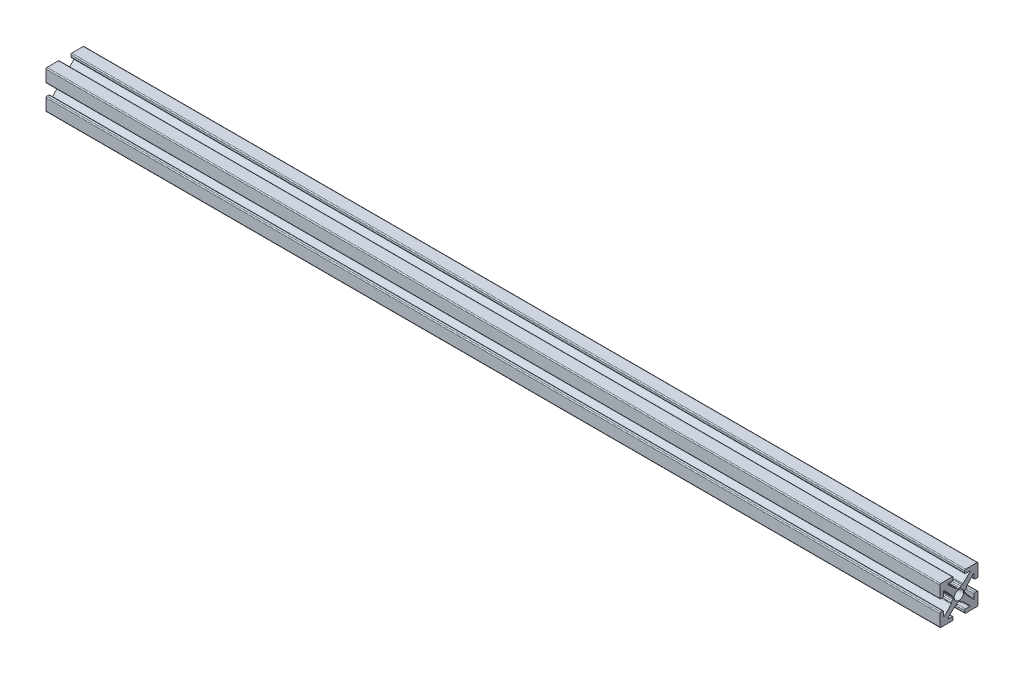
from build123d import *

# Parameters (mm, degrees)
ESTRUSIONE_ESTRUSIONE1_DEPTH = 234.4674
FORO_FILETTATO_M3X0_5_1_D    = 2.5


with BuildPart() as part:
    # Sketch1 → Estrusione-Estrusione1 (new body)
    with BuildSketch(Plane(origin=(0, 0, 0), x_dir=(0, 0, -1), z_dir=(1, 0, 0))):
        with BuildLine():
            Line((-0.2413, 1.4986), (0.2413, 1.4986))
            ThreePointArc((0.2413, 1.4986), (0.420905122, 1.572994878), (0.4953, 1.7526))
            ThreePointArc((0.4953, 1.7526), (0.569694878, 1.932205122), (0.7493, 2.0066))
            Line((0.7493, 2.0066), (0.889923986, 2.0066))
            ThreePointArc((0.889923986, 2.0066), (0.983516259, 2.024471886), (1.063937899, 2.075572548))
            Line((1.063937899, 2.075572548), (2.890793, 3.793686274))
            ThreePointArc((2.890793, 3.793686274), (2.921850101, 3.932996137), (2.803786044, 4.0132))
            Line((2.803786044, 4.0132), (1.7526, 4.0132))
            ThreePointArc((1.7526, 4.0132), (1.572994878, 4.087594878), (1.4986, 4.2672))
            Line((1.4986, 4.2672), (1.4986, 4.7498))
            ThreePointArc((1.4986, 4.7498), (1.572994878, 4.929405122), (1.7526, 5.0038))
            Line((1.7526, 5.0038), (4.7498, 5.0038))
            ThreePointArc((4.7498, 5.0038), (4.929405122, 4.929405122), (5.0038, 4.7498))
            Line((5.0038, 4.7498), (5.0038, 1.7526))
            ThreePointArc((5.0038, 1.7526), (4.929405122, 1.572994878), (4.7498, 1.4986))
            Line((4.7498, 1.4986), (4.2672, 1.4986))
            ThreePointArc((4.2672, 1.4986), (4.087594878, 1.572994878), (4.0132, 1.7526))
            Line((4.0132, 1.7526), (4.0132, 2.803786044))
            ThreePointArc((4.0132, 2.803786044), (3.932996137, 2.921850101), (3.793686274, 2.890793))
            Line((3.793686274, 2.890793), (2.075572548, 1.063937899))
            ThreePointArc((2.075572548, 1.063937899), (2.024471886, 0.983516259), (2.0066, 0.889923986))
            Line((2.0066, 0.889923986), (2.0066, 0.7493))
            ThreePointArc((2.0066, 0.7493), (1.932205122, 0.569694878), (1.7526, 0.4953))
            ThreePointArc((1.7526, 0.4953), (1.572994878, 0.420905122), (1.4986, 0.2413))
            Line((1.4986, 0.2413), (1.4986, -0.2413))
            ThreePointArc((1.4986, -0.2413), (1.572994878, -0.420905122), (1.7526, -0.4953))
            ThreePointArc((1.7526, -0.4953), (1.932205122, -0.569694878), (2.0066, -0.7493))
            Line((2.0066, -0.7493), (2.0066, -0.889923986))
            ThreePointArc((2.0066, -0.889923986), (2.024471886, -0.983516259), (2.075572548, -1.063937899))
            Line((2.075572548, -1.063937899), (3.793686274, -2.890793))
            ThreePointArc((3.793686274, -2.890793), (3.932996137, -2.921850101), (4.0132, -2.803786044))
            Line((4.0132, -2.803786044), (4.0132, -1.7526))
            ThreePointArc((4.0132, -1.7526), (4.087594878, -1.572994878), (4.2672, -1.4986))
            Line((4.2672, -1.4986), (4.7498, -1.4986))
            ThreePointArc((4.7498, -1.4986), (4.929405122, -1.572994878), (5.0038, -1.7526))
            Line((5.0038, -1.7526), (5.0038, -4.7498))
            ThreePointArc((5.0038, -4.7498), (4.929405122, -4.929405122), (4.7498, -5.0038))
            Line((4.7498, -5.0038), (1.7526, -5.0038))
            ThreePointArc((1.7526, -5.0038), (1.572994878, -4.929405122), (1.4986, -4.7498))
            Line((1.4986, -4.7498), (1.4986, -4.2672))
            ThreePointArc((1.4986, -4.2672), (1.572994878, -4.087594878), (1.7526, -4.0132))
            Line((1.7526, -4.0132), (2.803786044, -4.0132))
            ThreePointArc((2.803786044, -4.0132), (2.921850101, -3.932996137), (2.890793, -3.793686274))
            Line((2.890793, -3.793686274), (1.063937899, -2.075572548))
            ThreePointArc((1.063937899, -2.075572548), (0.983516259, -2.024471886), (0.889923986, -2.0066))
            Line((0.889923986, -2.0066), (0.7493, -2.0066))
            ThreePointArc((0.7493, -2.0066), (0.569694878, -1.932205122), (0.4953, -1.7526))
            ThreePointArc((0.4953, -1.7526), (0.420905122, -1.572994878), (0.2413, -1.4986))
            Line((0.2413, -1.4986), (-0.2413, -1.4986))
            ThreePointArc((-0.2413, -1.4986), (-0.420905122, -1.572994878), (-0.4953, -1.7526))
            ThreePointArc((-0.4953, -1.7526), (-0.569694878, -1.932205122), (-0.7493, -2.0066))
            Line((-0.7493, -2.0066), (-0.889923986, -2.0066))
            ThreePointArc((-0.889923986, -2.0066), (-0.983516259, -2.024471886), (-1.063937899, -2.075572548))
            Line((-1.063937899, -2.075572548), (-2.890793, -3.793686274))
            ThreePointArc((-2.890793, -3.793686274), (-2.921850101, -3.932996137), (-2.803786044, -4.0132))
            Line((-2.803786044, -4.0132), (-1.7526, -4.0132))
            ThreePointArc((-1.7526, -4.0132), (-1.572994878, -4.087594878), (-1.4986, -4.2672))
            Line((-1.4986, -4.2672), (-1.4986, -4.7498))
            ThreePointArc((-1.4986, -4.7498), (-1.572994878, -4.929405122), (-1.7526, -5.0038))
            Line((-1.7526, -5.0038), (-4.7498, -5.0038))
            ThreePointArc((-4.7498, -5.0038), (-4.929405122, -4.929405122), (-5.0038, -4.7498))
            Line((-5.0038, -4.7498), (-5.0038, -1.7526))
            ThreePointArc((-5.0038, -1.7526), (-4.929405122, -1.572994878), (-4.7498, -1.4986))
            Line((-4.7498, -1.4986), (-4.2672, -1.4986))
            ThreePointArc((-4.2672, -1.4986), (-4.087594878, -1.572994878), (-4.0132, -1.7526))
            Line((-4.0132, -1.7526), (-4.0132, -2.803786044))
            ThreePointArc((-4.0132, -2.803786044), (-3.932996137, -2.921850101), (-3.793686274, -2.890793))
            Line((-3.793686274, -2.890793), (-2.075572548, -1.063937899))
            ThreePointArc((-2.075572548, -1.063937899), (-2.024471886, -0.983516259), (-2.0066, -0.889923986))
            Line((-2.0066, -0.889923986), (-2.0066, -0.7493))
            ThreePointArc((-2.0066, -0.7493), (-1.932205122, -0.569694878), (-1.7526, -0.4953))
            ThreePointArc((-1.7526, -0.4953), (-1.572994878, -0.420905122), (-1.4986, -0.2413))
            Line((-1.4986, -0.2413), (-1.4986, 0.2413))
            ThreePointArc((-1.4986, 0.2413), (-1.572994878, 0.420905122), (-1.7526, 0.4953))
            ThreePointArc((-1.7526, 0.4953), (-1.932205122, 0.569694878), (-2.0066, 0.7493))
            Line((-2.0066, 0.7493), (-2.0066, 0.889923986))
            ThreePointArc((-2.0066, 0.889923986), (-2.024471886, 0.983516259), (-2.075572548, 1.063937899))
            Line((-2.075572548, 1.063937899), (-3.793686274, 2.890793))
            ThreePointArc((-3.793686274, 2.890793), (-3.932996137, 2.921850101), (-4.0132, 2.803786044))
            Line((-4.0132, 2.803786044), (-4.0132, 1.7526))
            ThreePointArc((-4.0132, 1.7526), (-4.087594878, 1.572994878), (-4.2672, 1.4986))
            Line((-4.2672, 1.4986), (-4.7498, 1.4986))
            ThreePointArc((-4.7498, 1.4986), (-4.929405122, 1.572994878), (-5.0038, 1.7526))
            Line((-5.0038, 1.7526), (-5.0038, 4.7498))
            ThreePointArc((-5.0038, 4.7498), (-4.929405122, 4.929405122), (-4.7498, 5.0038))
            Line((-4.7498, 5.0038), (-1.7526, 5.0038))
            ThreePointArc((-1.7526, 5.0038), (-1.572994878, 4.929405122), (-1.4986, 4.7498))
            Line((-1.4986, 4.7498), (-1.4986, 4.2672))
            ThreePointArc((-1.4986, 4.2672), (-1.572994878, 4.087594878), (-1.7526, 4.0132))
            Line((-1.7526, 4.0132), (-2.803786044, 4.0132))
            ThreePointArc((-2.803786044, 4.0132), (-2.921850101, 3.932996137), (-2.890793, 3.793686274))
            Line((-2.890793, 3.793686274), (-1.063937899, 2.075572548))
            ThreePointArc((-1.063937899, 2.075572548), (-0.983516259, 2.024471886), (-0.889923986, 2.0066))
            Line((-0.889923986, 2.0066), (-0.7493, 2.0066))
            ThreePointArc((-0.7493, 2.0066), (-0.569694878, 1.932205122), (-0.4953, 1.7526))
            ThreePointArc((-0.4953, 1.7526), (-0.420905122, 1.572994878), (-0.2413, 1.4986))
        make_face()
    extrude(amount=ESTRUSIONE_ESTRUSIONE1_DEPTH)

    # Foro filettato M3x0.5-1 (through all)
    with Locations(Plane.ZY):
        with Locations((0, 0)):
            Hole(FORO_FILETTATO_M3X0_5_1_D / 2)


solid = part.part
